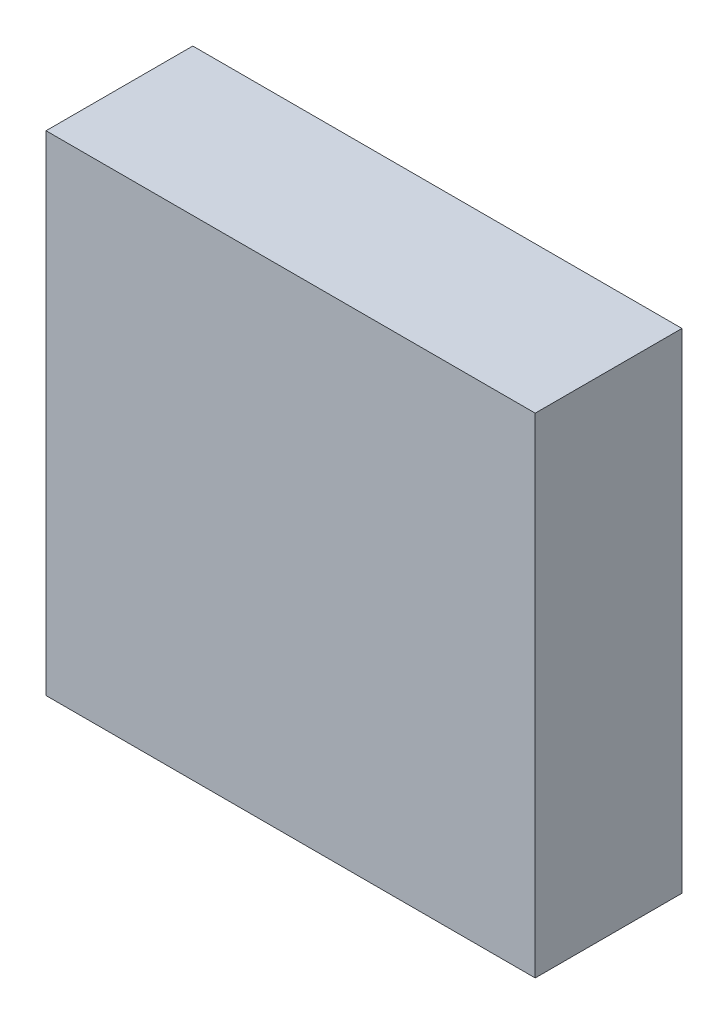
from build123d import *

# Parameters (mm, degrees)
SKETCH1_W           = 32
SKETCH1_H           = 32
BOSS_EXTRUDE1_DEPTH = 9.6


with BuildPart() as part:
    # Sketch1 → Boss-Extrude1 (new body)
    with BuildSketch(Plane(origin=(0, 0, 0), x_dir=(0, 1, 0), z_dir=(0, 0, 1))):
        with Locations((16, 16)):
            Rectangle(SKETCH1_W, SKETCH1_H)
    extrude(amount=BOSS_EXTRUDE1_DEPTH)


solid = part.part
